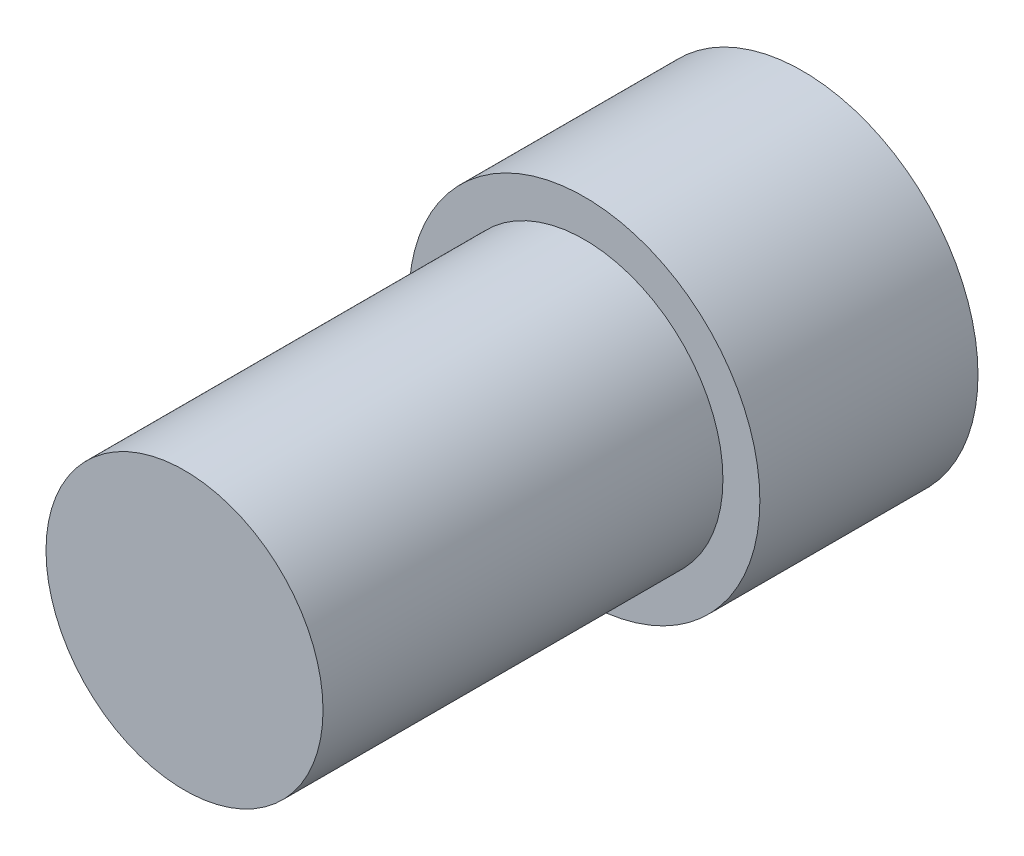
from build123d import *

# Parameters (mm, degrees)
SKETCH2_R           = 4.826
BOSS_EXTRUDE1_DEPTH = 6
SKETCH4_R           = 3.81
BOSS_EXTRUDE2_DEPTH = 11


with BuildPart() as part:
    # Sketch2 → Boss-Extrude1 (new body)
    with BuildSketch(Plane.XY):
        Circle(SKETCH2_R)
    extrude(amount=BOSS_EXTRUDE1_DEPTH)

    # Sketch4 → Boss-Extrude2 (add)
    with BuildSketch(Plane.XY.offset(6)):
        Circle(SKETCH4_R)
    extrude(amount=BOSS_EXTRUDE2_DEPTH)


solid = part.part
